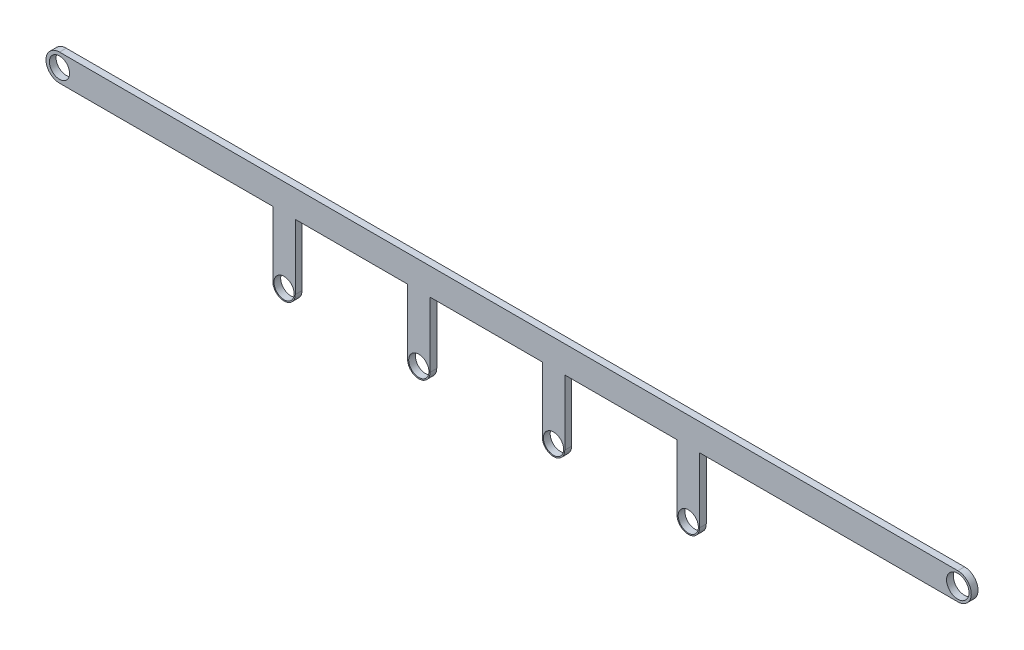
from build123d import *

# Parameters (mm, degrees)
SKETCH1_R           = 4.5
SKETCH1_R_2         = 5
BOSS_EXTRUDE2_DEPTH = 3


with BuildPart() as part:
    # Sketch1 → Boss-Extrude2 (new body)
    with BuildSketch(Plane.XY):
        with BuildLine():
            Line((400, 6), (0, 6))
            ThreePointArc((0, 6), (-6, 0), (0, -6))
            Line((0, -6), (95, -6))
            Line((95, -6), (95, -35))
            ThreePointArc((95, -35), (100, -40), (105, -35))
            Line((105, -35), (105, -6))
            Line((105, -6), (155, -6))
            Line((155, -6), (155, -35))
            ThreePointArc((155, -35), (160, -40), (165, -35))
            Line((165, -35), (165, -6))
            Line((165, -6), (215, -6))
            Line((215, -6), (215, -35))
            ThreePointArc((215, -35), (220, -40), (225, -35))
            Line((225, -35), (225, -6))
            Line((225, -6), (275, -6))
            Line((275, -6), (275, -35))
            ThreePointArc((275, -35), (280, -40), (285, -35))
            Line((285, -35), (285, -6))
            Line((285, -6), (400, -6))
            ThreePointArc((400, -6), (406, 0), (400, 6))
        make_face()
        Circle(SKETCH1_R, mode=Mode.SUBTRACT)
        with Locations((400, 0)):
            Circle(SKETCH1_R_2, mode=Mode.SUBTRACT)
        with Locations((100, -35)):
            Circle(SKETCH1_R, mode=Mode.SUBTRACT)
        with Locations((280, -35)):
            Circle(SKETCH1_R, mode=Mode.SUBTRACT)
        with Locations((160, -35)):
            Circle(SKETCH1_R, mode=Mode.SUBTRACT)
        with Locations((220, -35)):
            Circle(SKETCH1_R, mode=Mode.SUBTRACT)
    extrude(amount=BOSS_EXTRUDE2_DEPTH)


solid = part.part
